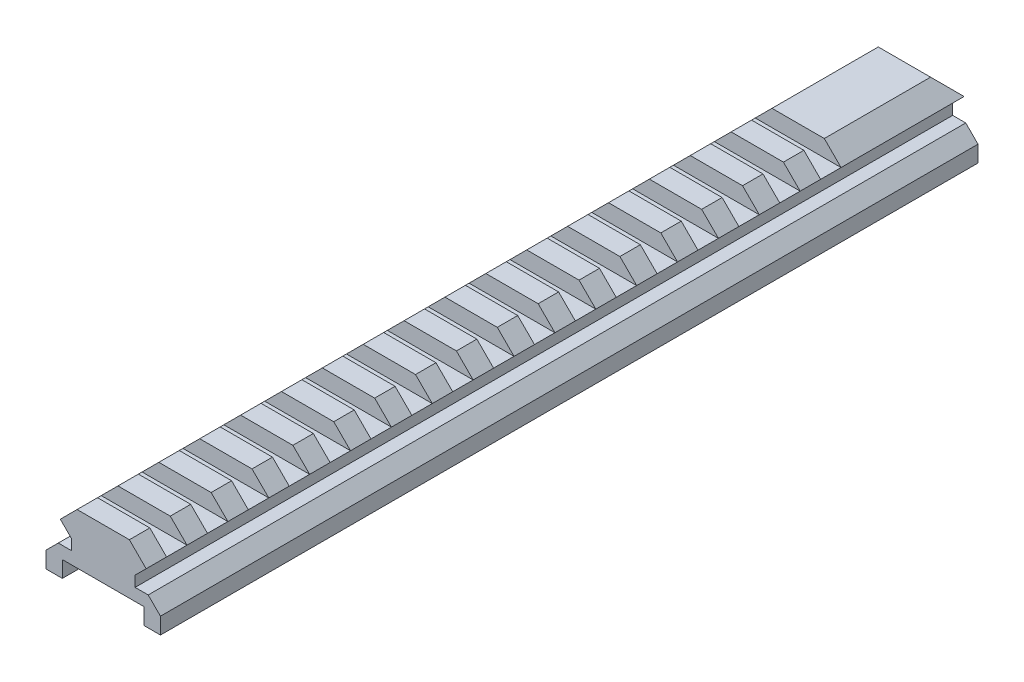
from build123d import *

# Parameters (mm, degrees)
BOSS_EXTRUDE1_DEPTH = 200
CHAMFER1_SIZE       = 3
SKETCH2_W           = 5
SKETCH2_H           = 4.1
CUT_EXTRUDE1_DEPTH  = 200
LPATTERN1_COUNT     = 20
LPATTERN1_PITCH     = 10
BOSS_EXTRUDE2_DEPTH = 25
CHAMFER2_SIZE       = 4


with BuildPart() as part:
    # Sketch1 → Boss-Extrude1 (new body)
    with BuildSketch(Plane.XY):
        Polygon((-14, 2.3), (-7.8, 2.3), (-7.8, 4.9), (-10.5, 7.6), (-6.4, 11.7), (6.4, 11.7), (10.5, 7.6), (7.8, 4.9), (7.8, 2.3), (14, 2.3), (14, -4.7), (10, -4.7), (10, -0.7), (-10, -0.7), (-10, -4.7), (-14, -4.7), align=None)
    extrude(amount=BOSS_EXTRUDE1_DEPTH)

    # Chamfer1
    chamfer1_edges = [part.edges().sort_by_distance(p)[0] for p in [
        (-14, 2.3, 100),
        (14, 2.3, 100),
    ]]
    chamfer(chamfer1_edges, length=CHAMFER1_SIZE)

    # Sketch2 → Cut-Extrude1 (cut, symmetric)
    with BuildSketch(Plane(origin=(0, 0, 0), x_dir=(0, 0, -1), z_dir=(1, 0, 0))):
        with Locations((-192.5, 9.65)):
            Rectangle(SKETCH2_W, SKETCH2_H)
    cut_extrude1 = extrude(amount=CUT_EXTRUDE1_DEPTH, both=True, mode=Mode.SUBTRACT)

    # LPattern1: Cut-Extrude1 ×20
    with Locations(*[(0, 0, -i * LPATTERN1_PITCH) for i in range(1, LPATTERN1_COUNT)]):
        add(cut_extrude1, mode=Mode.SUBTRACT)

    # Sketch4 → Boss-Extrude2 (add)
    with BuildSketch(Plane(origin=(0, 0, 25), x_dir=(-1, 0, 0), z_dir=(0, 0, -1))):
        Polygon((-10.5, 7.6), (10.5, 7.6), (6.4, 11.7), (-6.4, 11.7), align=None)
    extrude(amount=BOSS_EXTRUDE2_DEPTH)

    # Chamfer2
    chamfer2_edges = [part.edges().sort_by_distance(p)[0] for p in [
        (0, 11.7, 0),
    ]]
    chamfer(chamfer2_edges, length=CHAMFER2_SIZE)


solid = part.part
